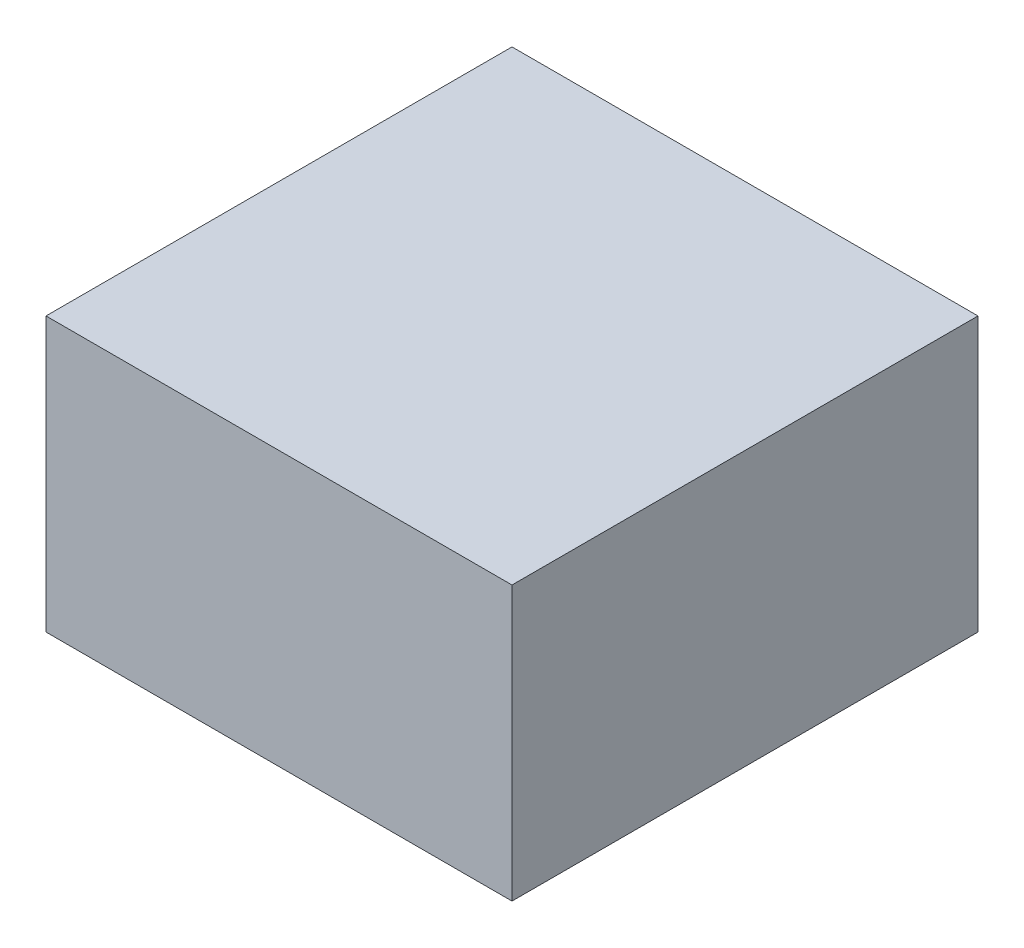
from build123d import *

# Parameters (mm, degrees)
SKETCH1_W           = 48
SKETCH1_H           = 48
BOSS_EXTRUDE1_DEPTH = 14.1


with BuildPart() as part:
    # Sketch1 → Boss-Extrude1 (new body, symmetric)
    with BuildSketch(Plane(origin=(0, 0, 0), x_dir=(1, 0, 0), z_dir=(0, 1, 0))):
        Rectangle(SKETCH1_W, SKETCH1_H)
    extrude(amount=BOSS_EXTRUDE1_DEPTH, both=True)


solid = part.part
